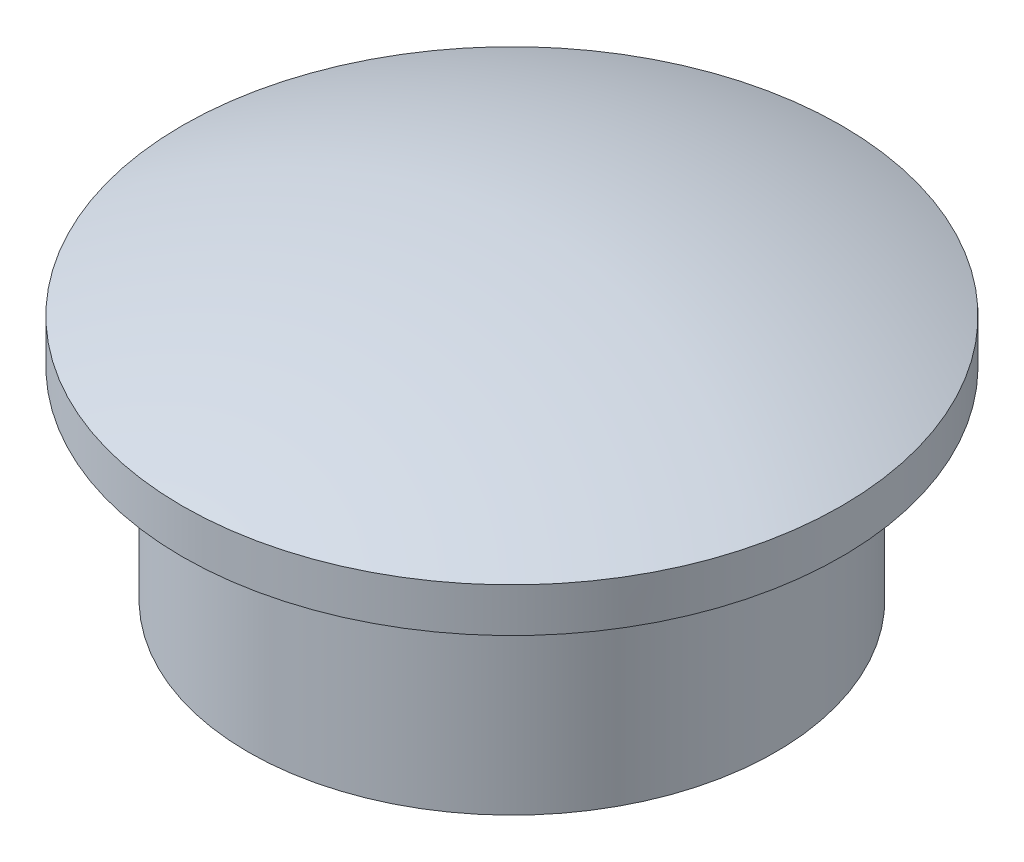
from build123d import *

# Parameters (mm, degrees)
SKETCH1_R           = 7.5
BOSS_EXTRUDE1_DEPTH = 1
SKETCH4_R           = 6
BOSS_EXTRUDE2_DEPTH = 4.6
SKETCH5_R           = 4.95
CUT_EXTRUDE1_DEPTH  = 5.6


with BuildPart() as part:
    # Sketch1 → Boss-Extrude1 (new body)
    with BuildSketch(Plane(origin=(0, 0, 0), x_dir=(1, 0, 0), z_dir=(0, 1, 0))):
        Circle(SKETCH1_R)
    extrude(amount=BOSS_EXTRUDE1_DEPTH)

    # Sketch2 one side → Revolve1 (revolve)
    with BuildSketch(Plane.XY):
        with BuildLine():
            Line((0, 1), (7.5, 1))
            ThreePointArc((7.5, 1), (3.829246009, 2.158448432), (0, 2.55))
            Line((0, 2.55), (0, 1))
        make_face()
    revolve(axis=Axis((0, 2.55, 0), (0, -1, 0)))

    # Sketch4 → Boss-Extrude2 (add)
    with BuildSketch(Plane.XZ):
        Circle(SKETCH4_R)
    extrude(amount=BOSS_EXTRUDE2_DEPTH)

    # Sketch5 → Cut-Extrude1 (cut)
    with BuildSketch(Plane.XZ.offset(4.6)):
        Circle(SKETCH5_R)
    extrude(amount=-CUT_EXTRUDE1_DEPTH, mode=Mode.SUBTRACT)


solid = part.part
